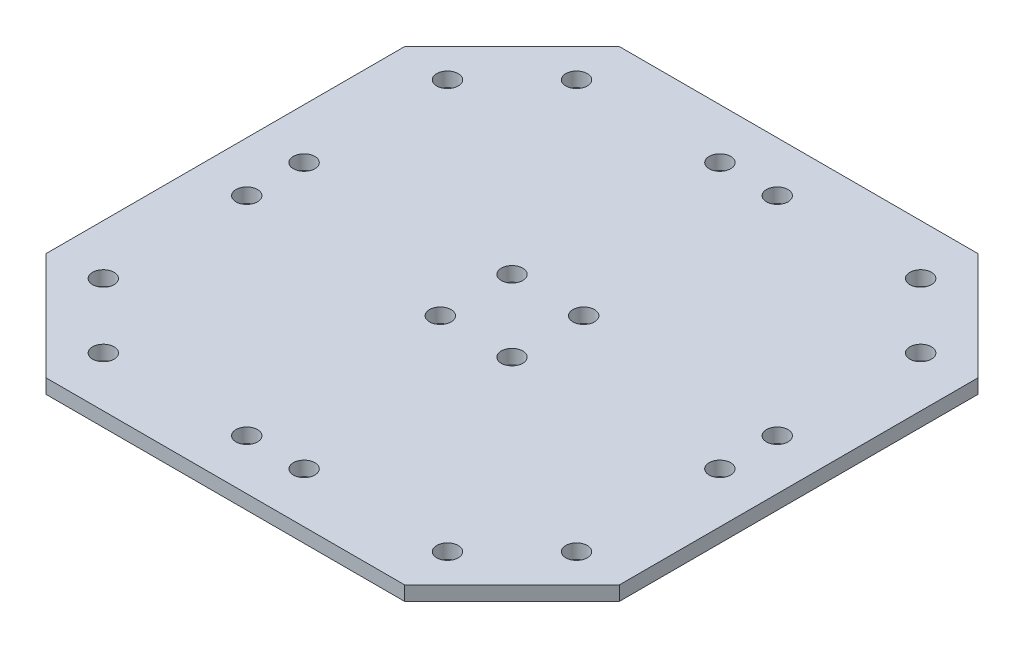
from build123d import *

# Parameters (mm, degrees)
BOSS_EXTRUDE1_DEPTH                        = 2
SKETCH6_R                                  = 1.5
CUT_EXTRUDE3_DEPTH                         = 4
MIRROR2_AT_THE_SECOND_PLANE_COPY_1_DEPTH   = 2
MIRROR2_AT_THE_SECOND_PLANE_COPY_2_SKETC_R = 1.5
MIRROR2_AT_THE_SECOND_PLANE_COPY_2_DEPTH   = 4


with BuildPart() as part:
    # Sketch1 → Boss-Extrude1 (new body)
    with BuildSketch(Plane(origin=(0, 0, 0), x_dir=(1, 0, 0), z_dir=(0, 1, 0))):
        Polygon((25, 40), (40, 25), (40, 0), (0, 0), (0, 40), align=None)
    boss_extrude1 = extrude(amount=BOSS_EXTRUDE1_DEPTH)

    # Sketch6 → Cut-Extrude3 (cut, through all)
    with BuildSketch(Plane(origin=(0, 3, 0), x_dir=(1, 0, 0), z_dir=(0, 1, 0))):
        with Locations((33, 24)):
            Circle(SKETCH6_R)
        with Locations((24, 33)):
            Circle(SKETCH6_R)
        with Locations((4, 33)):
            Circle(SKETCH6_R)
        with Locations((33, 4)):
            Circle(SKETCH6_R)
        with Locations((5, 5)):
            Circle(SKETCH6_R)
    cut_extrude3 = extrude(amount=-CUT_EXTRUDE3_DEPTH, mode=Mode.SUBTRACT)

    # Mirror2: Boss-Extrude1, Cut-Extrude3 across plane
    add(boss_extrude1.mirror(Plane(origin=(0, 0, 0), x_dir=(0, 0, 1), z_dir=(1, 0, 0))))
    add(cut_extrude3.mirror(Plane(origin=(0, 0, 0), x_dir=(0, 0, 1), z_dir=(1, 0, 0))), mode=Mode.SUBTRACT)

    # Mirror2 at the second plane: Boss-Extrude1, Cut-Extrude3 across plane
    add(boss_extrude1.mirror(Plane.XY))
    add(cut_extrude3.mirror(Plane.XY), mode=Mode.SUBTRACT)

    # Mirror2 at the second plane copy 1 sketc → Mirror2 at the second plane copy 1 (add)
    with BuildSketch(Plane(origin=(0, 0, 0), x_dir=(-1, 0, 0), z_dir=(0, 1, 0))):
        Polygon((25, 40), (40, 25), (40, 0), (0, 0), (0, 40), align=None)
    extrude(amount=MIRROR2_AT_THE_SECOND_PLANE_COPY_1_DEPTH)

    # Mirror2 at the second plane copy 2 sketc → Mirror2 at the second plane copy 2 (cut, through all)
    with BuildSketch(Plane(origin=(0, 3, 0), x_dir=(-1, 0, 0), z_dir=(0, 1, 0))):
        with Locations((33, 24)):
            Circle(MIRROR2_AT_THE_SECOND_PLANE_COPY_2_SKETC_R)
        with Locations((24, 33)):
            Circle(MIRROR2_AT_THE_SECOND_PLANE_COPY_2_SKETC_R)
        with Locations((4, 33)):
            Circle(MIRROR2_AT_THE_SECOND_PLANE_COPY_2_SKETC_R)
        with Locations((33, 4)):
            Circle(MIRROR2_AT_THE_SECOND_PLANE_COPY_2_SKETC_R)
        with Locations((5, 5)):
            Circle(MIRROR2_AT_THE_SECOND_PLANE_COPY_2_SKETC_R)
    extrude(amount=-MIRROR2_AT_THE_SECOND_PLANE_COPY_2_DEPTH, mode=Mode.SUBTRACT)


solid = part.part
